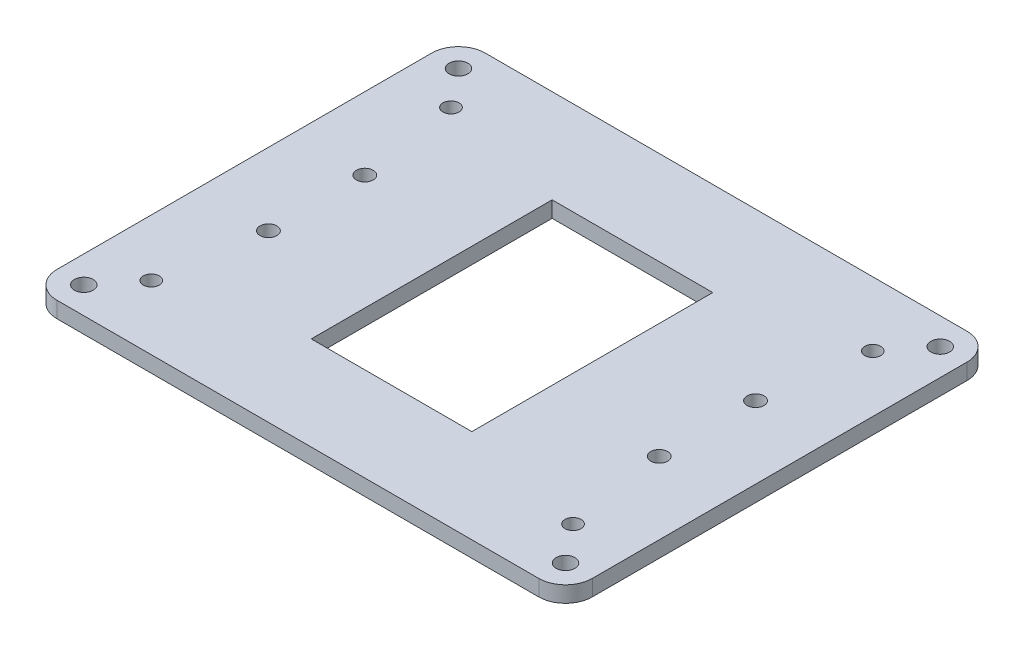
from build123d import *

# Parameters (mm, degrees)
BOSS_EXTRUDE1_DEPTH  = 3
SKETCH2_R            = 1.575
CUT_EXTRUDE1_DEPTH   = 4
SKETCH3_R            = 1.75
CUT_EXTRUDE2_DEPTH   = 4
LPATTERN1_COUNT      = 2
LPATTERN1_PITCH      = 70
LPATTERN1_COUNT_DIR2 = 2
LPATTERN1_PITCH_DIR2 = 90
SKETCH4_R            = 1.5
CUT_EXTRUDE3_DEPTH   = 4
SKETCH5_W            = 30
SKETCH5_H            = 45
CUT_EXTRUDE4_DEPTH   = 4


with BuildPart() as part:
    # Sketch1 → Boss-Extrude1 (new body)
    with BuildSketch(Plane(origin=(0, 0, 0), x_dir=(1, 0, 0), z_dir=(0, 1, 0))):
        with BuildLine():
            Line((-45, 40), (45, 40))
            ThreePointArc((45, 40), (48.535533906, 38.535533906), (50, 35))
            Line((50, 35), (50, -35))
            ThreePointArc((50, -35), (48.535533906, -38.535533906), (45, -40))
            Line((45, -40), (-45, -40))
            ThreePointArc((-45, -40), (-48.535533906, -38.535533906), (-50, -35))
            Line((-50, -35), (-50, 35))
            ThreePointArc((-50, 35), (-48.535533906, 38.535533906), (-45, 40))
        make_face()
    extrude(amount=BOSS_EXTRUDE1_DEPTH)

    # Sketch2 → Cut-Extrude1 (cut)
    with BuildSketch(Plane(origin=(0, 3, 0), x_dir=(1, 0, 0), z_dir=(0, 1, 0))):
        with Locations((-36.5, 9)):
            Circle(SKETCH2_R)
        with Locations((-36.5, -9)):
            Circle(SKETCH2_R)
        with Locations((36.5, -9)):
            Circle(SKETCH2_R)
        with Locations((36.5, 9)):
            Circle(SKETCH2_R)
    extrude(amount=-CUT_EXTRUDE1_DEPTH, mode=Mode.SUBTRACT)

    # Sketch3 → Cut-Extrude2 (cut, through all)
    with BuildSketch(Plane(origin=(0, 3, 0), x_dir=(1, 0, 0), z_dir=(0, 1, 0))):
        with Locations((-45, -35)):
            Circle(SKETCH3_R)
    cut_extrude2 = extrude(amount=-CUT_EXTRUDE2_DEPTH, mode=Mode.SUBTRACT)

    # LPattern1: Cut-Extrude2 2 × 2
    with Locations(*[(j * LPATTERN1_PITCH_DIR2, 0, -i * LPATTERN1_PITCH) for i in range(LPATTERN1_COUNT) for j in range(LPATTERN1_COUNT_DIR2) if (i, j) != (0, 0)]):
        add(cut_extrude2, mode=Mode.SUBTRACT)

    # Sketch4 → Cut-Extrude3 (cut, through all)
    with BuildSketch(Plane(origin=(0, 3, 0), x_dir=(1, 0, 0), z_dir=(0, 1, 0))):
        with Locations((-39.4, 28)):
            Circle(SKETCH4_R)
        with Locations((39.4, 28)):
            Circle(SKETCH4_R)
        with Locations((39.4, -28)):
            Circle(SKETCH4_R)
        with Locations((-39.4, -28)):
            Circle(SKETCH4_R)
    extrude(amount=-CUT_EXTRUDE3_DEPTH, mode=Mode.SUBTRACT)

    # Sketch5 → Cut-Extrude4 (cut, through all)
    with BuildSketch(Plane(origin=(0, 3, 0), x_dir=(1, 0, 0), z_dir=(0, 1, 0))):
        Rectangle(SKETCH5_W, SKETCH5_H)
    extrude(amount=-CUT_EXTRUDE4_DEPTH, mode=Mode.SUBTRACT)


solid = part.part
